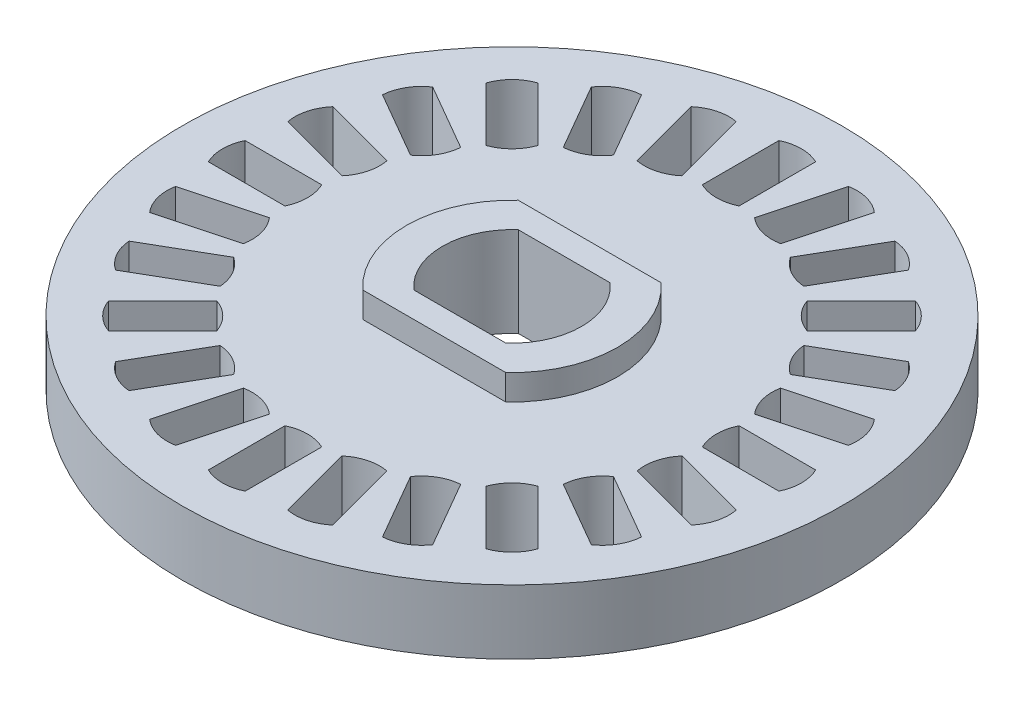
from build123d import *

# Parameters (mm, degrees)
SKETCH_1_R               = 12.91
EXTRUDE_1_DEPTH          = 2.52
EXTRUDE_2_DEPTH          = 1
CUT_EXTRUDE_1_DEPTH      = 4
CUT_EXTRUDE_2_DEPTH      = 4
PATTERN_CIRCULAR_1_COUNT = 24


with BuildPart() as part:
    # 草图1 → 凸台-拉伸1 (new body)
    with BuildSketch(Plane(origin=(0, 0, 0), x_dir=(1, 0, 0), z_dir=(0, 1, 0))):
        with Locations(Location((0, 0, 0), (0, 0, 270))):
            Circle(SKETCH_1_R)
    extrude(amount=EXTRUDE_1_DEPTH)

    # 草图2 → 凸台-拉伸2 (add)
    with BuildSketch(Plane(origin=(0, 2.52, 0), x_dir=(1, 0, 0), z_dir=(0, 1, 0))):
        with BuildLine():
            Line((-2.8, 3.045), (2.8, 3.045))
            ThreePointArc((2.8, 3.045), (4.136668345, 0), (2.8, -3.045))
            Line((2.8, -3.045), (-2.8, -3.045))
            ThreePointArc((-2.8, -3.045), (-4.136668345, 0), (-2.8, 3.045))
        make_face()
    extrude(amount=EXTRUDE_2_DEPTH)

    # 草图3 → 切除-拉伸1 (cut)
    with BuildSketch(Plane(origin=(0, 3.52, 0), x_dir=(1, 0, 0), z_dir=(0, 1, 0))):
        with BuildLine():
            Line((-1.8, -2.045), (1.8, -2.045))
            ThreePointArc((1.8, -2.045), (2.724339369, 0), (1.8, 2.045))
            Line((1.8, 2.045), (-1.8, 2.045))
            ThreePointArc((-1.8, 2.045), (-2.724339369, 0), (-1.8, -2.045))
        make_face()
    extrude(amount=-CUT_EXTRUDE_1_DEPTH, mode=Mode.SUBTRACT)

    # 草图4 → 切除-拉伸2 (cut)
    with BuildSketch(Plane(origin=(0, 2.52, 0), x_dir=(1, 0, 0), z_dir=(0, 1, 0))):
        with BuildLine():
            Line((-11.175157972, -0.72), (-8.175157972, -0.72))
            ThreePointArc((-8.175157972, -0.72), (-8.011307018, 0), (-8.175157972, 0.72))
            Line((-8.175157972, 0.72), (-11.175157972, 0.72))
            ThreePointArc((-11.175157972, 0.72), (-11.339008927, 0), (-11.175157972, -0.72))
        make_face()
    cut_extrude_2 = extrude(amount=-CUT_EXTRUDE_2_DEPTH, mode=Mode.SUBTRACT)

    # 阵列(圆周)1: 切除-拉伸2 ×24 about axis
    pattern_circular_1_axis = Axis((0, 0, 0), (0, 1, 0))
    for i in range(1, PATTERN_CIRCULAR_1_COUNT):
        add(cut_extrude_2.rotate(pattern_circular_1_axis, i * 360 / PATTERN_CIRCULAR_1_COUNT), mode=Mode.SUBTRACT)


solid = part.part
